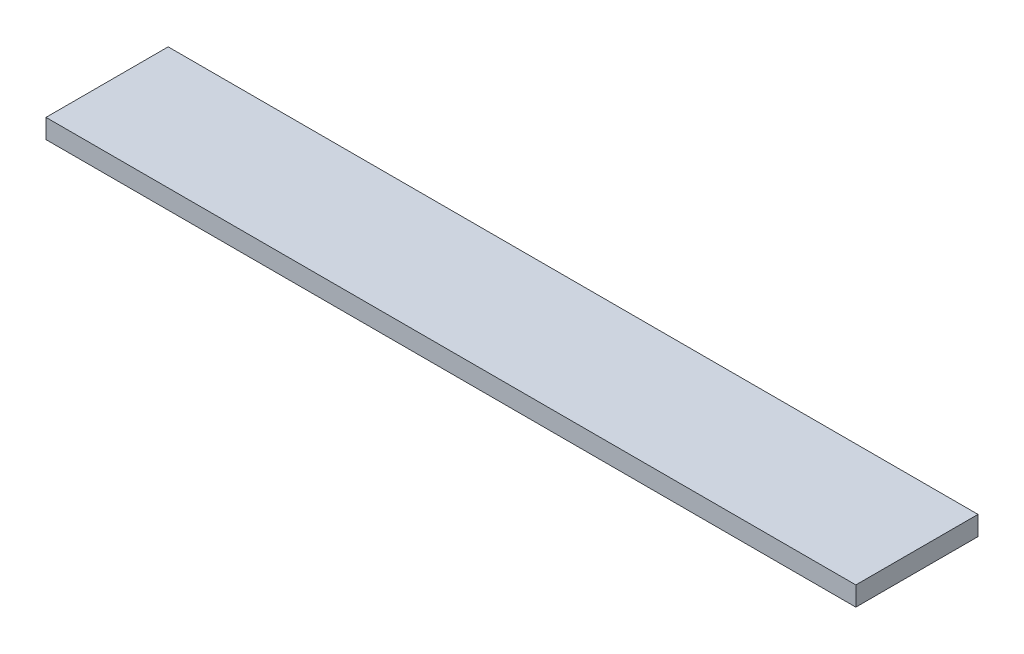
from build123d import *

# Parameters (mm, degrees)
SKETCH1_W           = 800.1
SKETCH1_H           = 120.7008
BOSS_EXTRUDE1_DEPTH = 19.05


with BuildPart() as part:
    # Sketch1 → Boss-Extrude1 (new body)
    with BuildSketch(Plane(origin=(0, 0, 0), x_dir=(1, 0, 0), z_dir=(0, 1, 0))):
        with Locations((400.05, 60.3504)):
            Rectangle(SKETCH1_W, SKETCH1_H)
    extrude(amount=BOSS_EXTRUDE1_DEPTH)


solid = part.part
